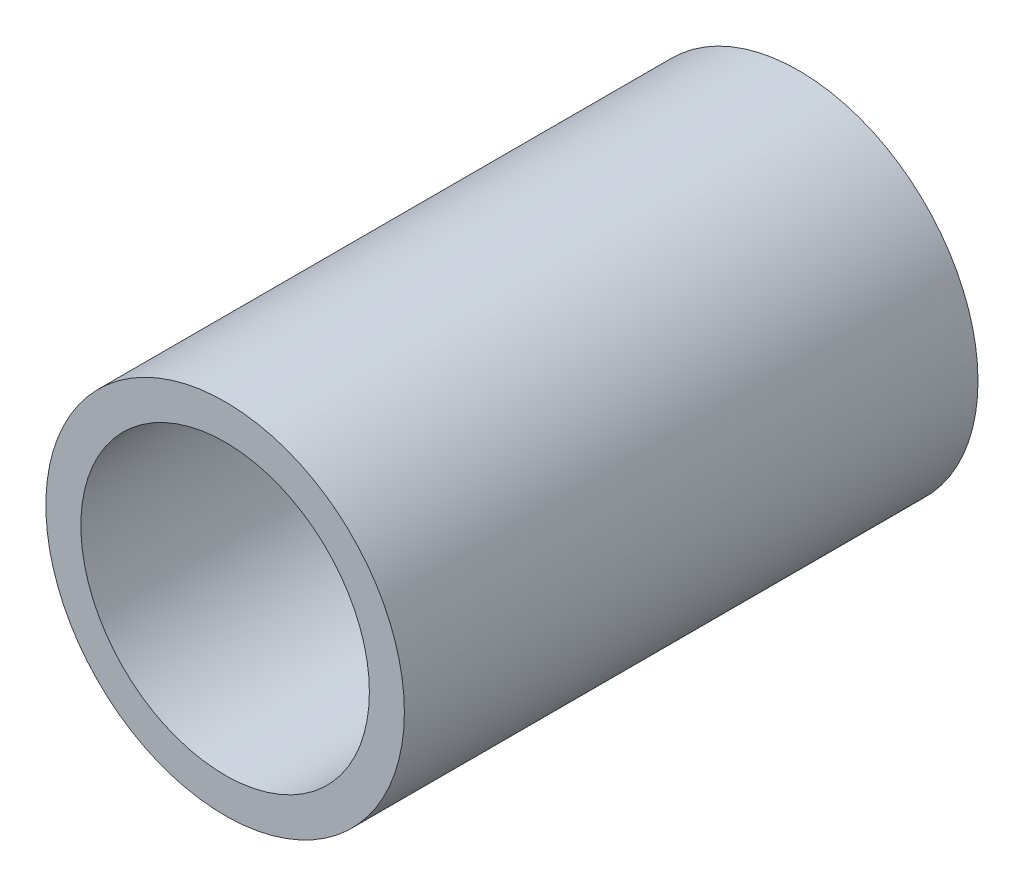
from build123d import *

# Parameters (mm, degrees)
SKETCH1_R      = 7.9375
SKETCH1_R_2    = 6.3881
EXTRUDE1_DEPTH = 12.7


with BuildPart() as part:
    # Sketch1 → Extrude1 (new body, symmetric)
    with BuildSketch(Plane.XY):
        Circle(SKETCH1_R)
        Circle(SKETCH1_R_2, mode=Mode.SUBTRACT)
    extrude(amount=EXTRUDE1_DEPTH, both=True)


solid = part.part
